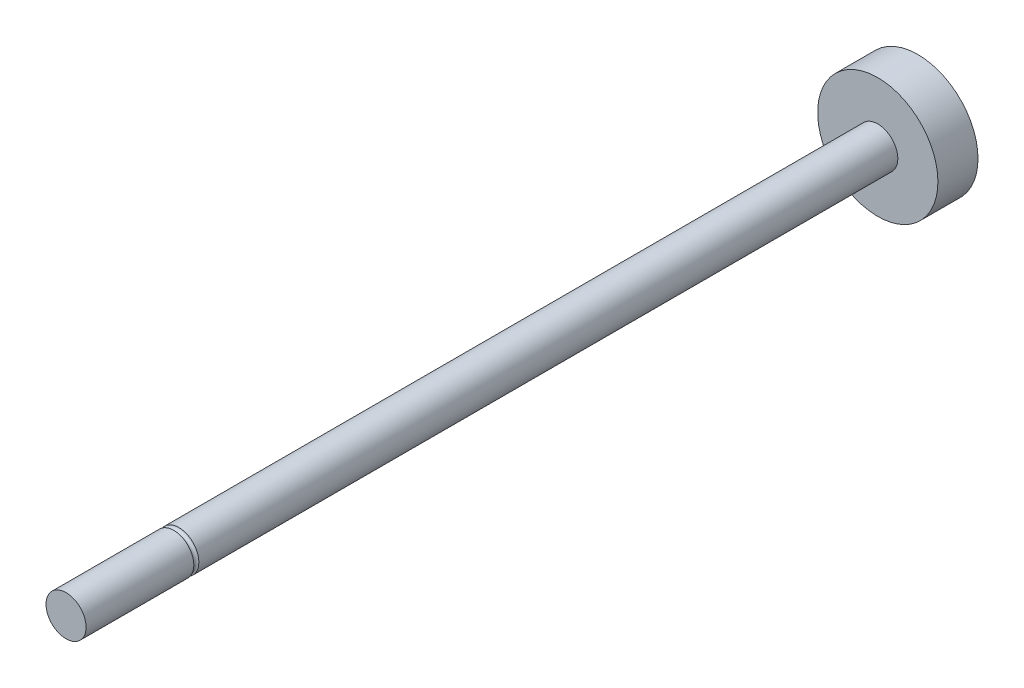
from build123d import *

# Parameters (mm, degrees)
SKETCH1_R           = 6
BOSS_EXTRUDE1_DEPTH = 4
SKETCH2_R           = 2
BOSS_EXTRUDE2_DEPTH = 85
SKETCH3_R           = 0.25


with BuildPart() as part:
    # Sketch1 → Boss-Extrude1 (new body)
    with BuildSketch(Plane.XY):
        Circle(SKETCH1_R)
    extrude(amount=BOSS_EXTRUDE1_DEPTH)

    # Sketch2 → Boss-Extrude2 (add)
    with BuildSketch(Plane.XY):
        Circle(SKETCH2_R)
    extrude(amount=BOSS_EXTRUDE2_DEPTH)

    # Sketch3 → Cut-Revolve1 (revolve, cut)
    with BuildSketch(Plane(origin=(0, 0, 0), x_dir=(0, 0, -1), z_dir=(1, 0, 0))):
        with Locations((-74, 2)):
            Circle(SKETCH3_R)
    revolve(axis=Axis((0, 0, 0), (0, 0, 1)), mode=Mode.SUBTRACT)


solid = part.part
